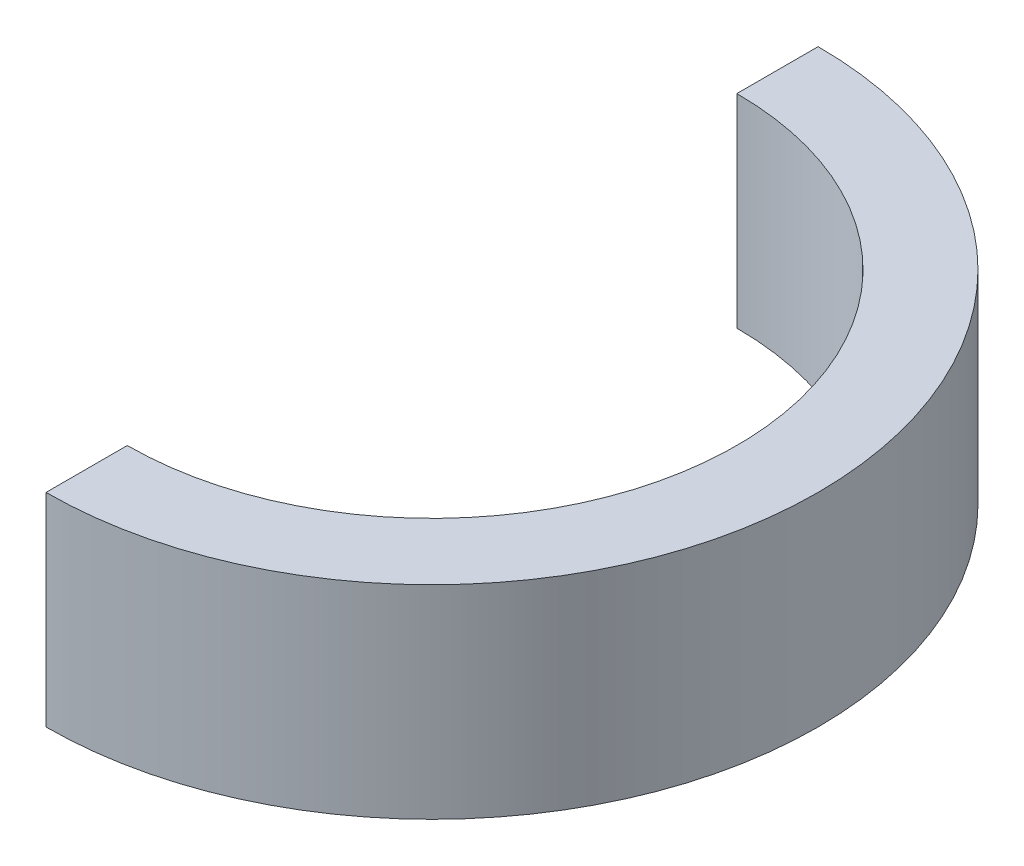
from build123d import *

# Parameters (mm, degrees)
EXTRUDE_1_DEPTH = 20


with BuildPart() as part:
    # 草图1 → 凸台-拉伸1 (new body)
    with BuildSketch(Plane(origin=(0, 0, 0), x_dir=(1, 0, 0), z_dir=(0, 1, 0))):
        with BuildLine():
            Line((0, 38), (0, 30))
            ThreePointArc((0, 30), (30, 0), (0, -30))
            Line((0, -30), (0, -38))
            ThreePointArc((0, -38), (38, 0), (0, 38))
        make_face()
    extrude(amount=EXTRUDE_1_DEPTH)


solid = part.part
